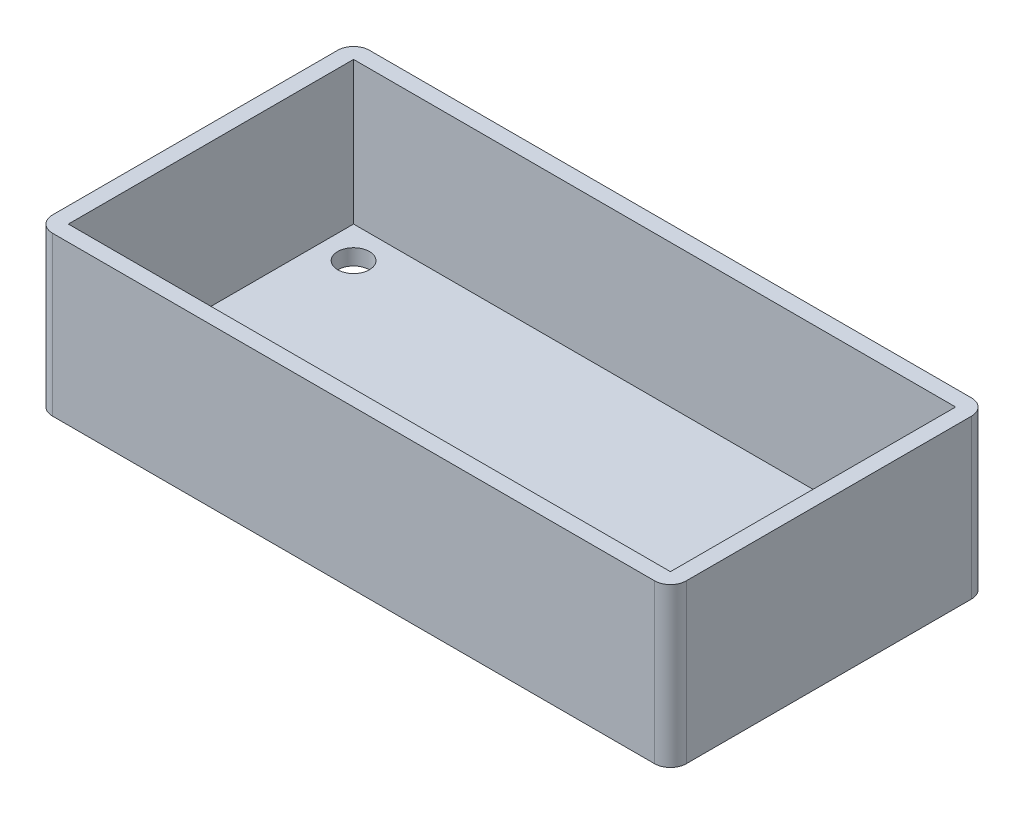
from build123d import *

# Parameters (mm, degrees)
SKETCH1_W           = 200
SKETCH1_H           = 100
BOSS_EXTRUDE1_DEPTH = 50
SHELL1_T            = -5
FILLET1_R           = 5
SKETCH5_R           = 5
CUT_EXTRUDE1_DEPTH  = 6


with BuildPart() as part:
    # Sketch1 → Boss-Extrude1 (new body)
    with BuildSketch(Plane(origin=(0, 0, 0), x_dir=(1, 0, 0), z_dir=(0, 1, 0))):
        Rectangle(SKETCH1_W, SKETCH1_H)
    extrude(amount=BOSS_EXTRUDE1_DEPTH)

    # Shell1
    shell1_openings = [part.faces().sort_by_distance(p)[0] for p in [
        (0, 50, 0),
    ]]
    offset(amount=SHELL1_T, openings=shell1_openings, kind=Kind.INTERSECTION)

    # Fillet1
    fillet1_edges = [part.edges().sort_by_distance(p)[0] for p in [
        (-100, 25, -50),
        (100, 25, -50),
        (100, 25, 50),
        (-100, 25, 50),
    ]]
    fillet(fillet1_edges, radius=FILLET1_R)

    # Sketch5 → Cut-Extrude1 (cut, through all)
    with BuildSketch(Plane(origin=(0, 5, 0), x_dir=(1, 0, 0), z_dir=(0, 1, 0))):
        with Locations((-85, 35)):
            Circle(SKETCH5_R)
        with Locations((85, 35)):
            Circle(SKETCH5_R)
        with Locations((85, -35)):
            Circle(SKETCH5_R)
        with Locations((-85, -35)):
            Circle(SKETCH5_R)
    extrude(amount=-CUT_EXTRUDE1_DEPTH, mode=Mode.SUBTRACT)


solid = part.part
